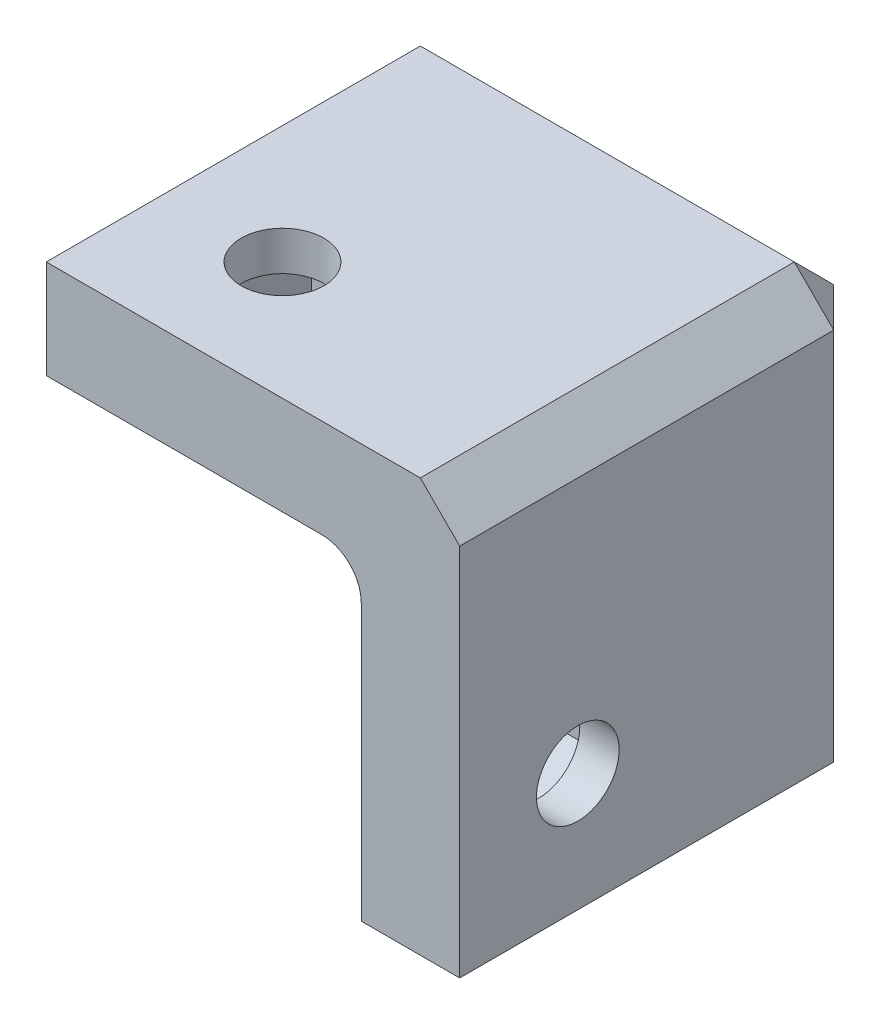
from build123d import *

# Parameters (mm, degrees)
SKETCH1_W           = 21
SKETCH1_H           = 21
BOSS_EXTRUDE1_DEPTH = 5
BOSS_EXTRUDE2_DEPTH = 16
SKETCH3_R           = 2.1
CUT_EXTRUDE1_DEPTH  = 3
SKETCH4_R           = 2.1
CUT_EXTRUDE2_DEPTH  = 3
SKETCH5_R           = 2.1
CUT_EXTRUDE3_DEPTH  = 3
CUT_EXTRUDE4_DEPTH  = 3
CUT_EXTRUDE5_DEPTH  = 3
CUT_EXTRUDE6_DEPTH  = 3
CHAMFER1_SIZE       = 2
FILLET1_R           = 2


with BuildPart() as part:
    # Sketch1 → Boss-Extrude1 (new body)
    with BuildSketch(Plane.XY):
        with Locations((10.5, 10.5)):
            Rectangle(SKETCH1_W, SKETCH1_H)
    extrude(amount=BOSS_EXTRUDE1_DEPTH)

    # Sketch2 → Boss-Extrude2 (add)
    with BuildSketch(Plane.XY.offset(5)):
        Polygon((0, 21), (21, 21), (21, 0), (16, 0), (16, 16), (0, 16), align=None)
    extrude(amount=BOSS_EXTRUDE2_DEPTH)

    # Sketch3 → Cut-Extrude1 (cut)
    with BuildSketch(Plane(origin=(0, 21, 0), x_dir=(1, 0, 0), z_dir=(0, 1, 0))):
        with Locations((6, -15)):
            Circle(SKETCH3_R)
    extrude(amount=-CUT_EXTRUDE1_DEPTH, mode=Mode.SUBTRACT)

    # Sketch4 → Cut-Extrude2 (cut)
    with BuildSketch(Plane(origin=(21, 0, 0), x_dir=(0, 0, -1), z_dir=(1, 0, 0))):
        with Locations((-15, 6)):
            Circle(SKETCH4_R)
    extrude(amount=-CUT_EXTRUDE2_DEPTH, mode=Mode.SUBTRACT)

    # Sketch5 → Cut-Extrude3 (cut)
    with BuildSketch(Plane(origin=(0, 0, 0), x_dir=(-1, 0, 0), z_dir=(0, 0, -1))):
        with Locations((-6, 6)):
            Circle(SKETCH5_R)
    extrude(amount=-CUT_EXTRUDE3_DEPTH, mode=Mode.SUBTRACT)

    # Sketch6 → Cut-Extrude4 (cut)
    with BuildSketch(Plane.ZY.offset(-16)):
        Polygon((18.5, 3.979274058), (18.5, 8.020725942), (15, 10.041451884), (11.5, 8.020725942), (11.5, 3.979274058), (15, 1.958548116), align=None)
    extrude(amount=-CUT_EXTRUDE4_DEPTH, mode=Mode.SUBTRACT)

    # Sketch7 → Cut-Extrude5 (cut)
    with BuildSketch(Plane.XY.offset(5)):
        Polygon((9.5, 3.979274058), (9.5, 8.020725942), (6, 10.041451884), (2.5, 8.020725942), (2.5, 3.979274058), (6, 1.958548116), align=None)
    extrude(amount=-CUT_EXTRUDE5_DEPTH, mode=Mode.SUBTRACT)

    # Sketch8 → Cut-Extrude6 (cut)
    with BuildSketch(Plane.XZ.offset(-16)):
        Polygon((8.020725942, 11.5), (10.041451884, 15), (8.020725942, 18.5), (3.979274058, 18.5), (1.958548116, 15), (3.979274058, 11.5), align=None)
    extrude(amount=-CUT_EXTRUDE6_DEPTH, mode=Mode.SUBTRACT)

    # Chamfer1
    chamfer1_edges = [part.edges().sort_by_distance(p)[0] for p in [
        (10.5, 21, 0),
        (21, 10.5, 0),
        (21, 21, 10.5),
    ]]
    chamfer(chamfer1_edges, length=CHAMFER1_SIZE)

    # Fillet1
    fillet1_edges = [part.edges().sort_by_distance(p)[0] for p in [
        (8, 16, 5),
        (16, 8, 5),
        (16, 16, 13),
    ]]
    fillet(fillet1_edges, radius=FILLET1_R)


solid = part.part
